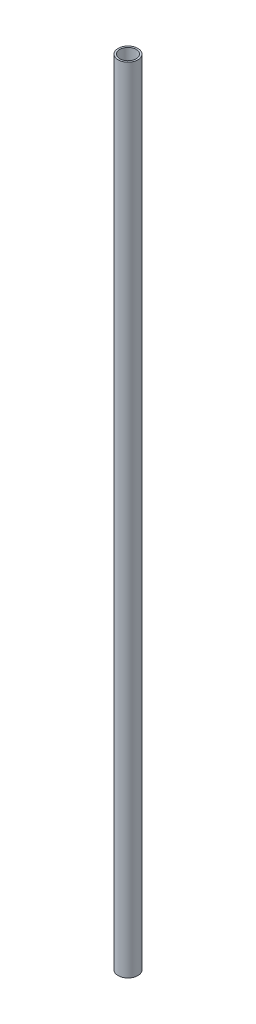
from build123d import *

# Parameters (mm, degrees)
SKETCH_1_R          = 4.25
EXTRUDE_1_DEPTH     = 340
SKETCH_2_R          = 3.5
CUT_EXTRUDE_1_DEPTH = 494


with BuildPart() as part:
    # 草图1 → 凸台-拉伸1 (new body)
    with BuildSketch(Plane(origin=(0, 0, 0), x_dir=(1, 0, 0), z_dir=(0, 1, 0))):
        Circle(SKETCH_1_R)
    extrude(amount=EXTRUDE_1_DEPTH)

    # 草图2 → 切除-拉伸1 (cut)
    with BuildSketch(Plane(origin=(0, 0, 0), x_dir=(1, 0, 0), z_dir=(0, 1, 0))):
        Circle(SKETCH_2_R)
    extrude(amount=CUT_EXTRUDE_1_DEPTH, mode=Mode.SUBTRACT)


solid = part.part
